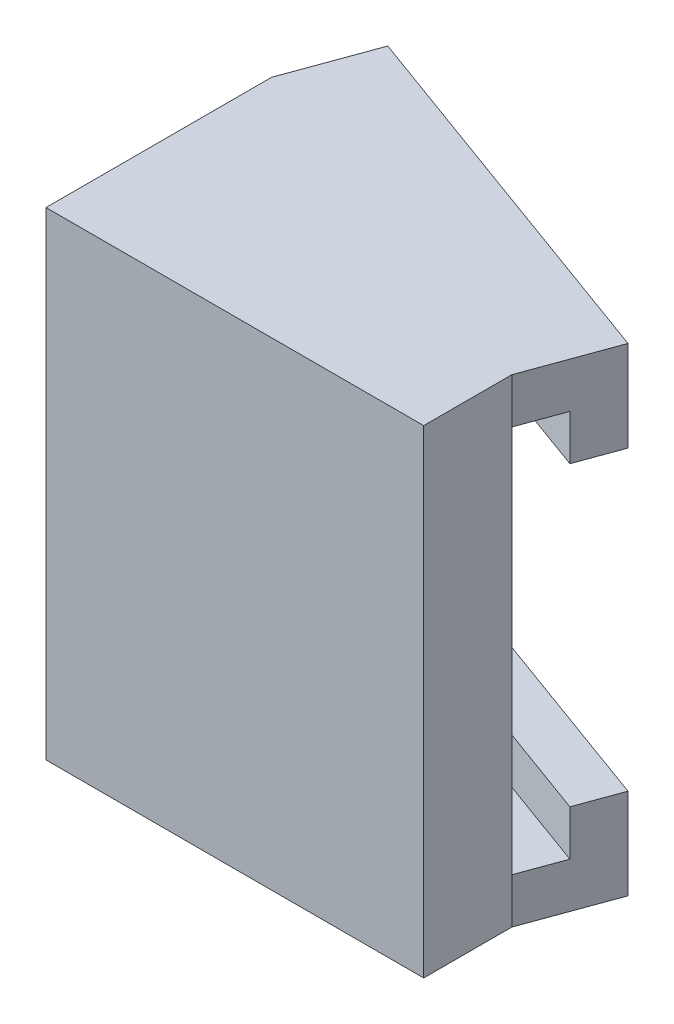
from build123d import *

# Parameters (mm, degrees)
SKIZZE1_W                       = 15
SKIZZE1_H                       = 19
AUFSATZ_LINEAR_AUSTRAGEN1_DEPTH = 3
AUFSATZ_LINEAR_AUSTRAGEN2_DEPTH = 19
SKIZZE5_R                       = 3
SCHNITT_LINEAR_AUSTRAGEN1_DEPTH = 3
SKIZZE6_W                       = 15
SKIZZE6_H                       = 19
AUFSATZ_LINEAR_AUSTRAGEN3_DEPTH = 0.5
SKIZZE7_W                       = 15.962666587
SKIZZE7_H                       = 1.8
AUFSATZ_LINEAR_AUSTRAGEN4_DEPTH = 3.6
AUFSATZ_LINEAR_AUSTRAGEN5_DEPTH = 1.8
AUFSATZ_LINEAR_AUSTRAGEN6_DEPTH = 1.8


with BuildPart() as part:
    # Skizze1 → Aufsatz-Linear austragen1 (new body)
    with BuildSketch(Plane.XY):
        Rectangle(SKIZZE1_W, SKIZZE1_H)
    extrude(amount=AUFSATZ_LINEAR_AUSTRAGEN1_DEPTH)

    # Skizze3 → Aufsatz-Linear austragen2 (add)
    with BuildSketch(Plane(origin=(0, 9.5, 0), x_dir=(1, 0, 0), z_dir=(0, 1, 0))):
        Polygon((-7.5, 0), (-7.5, 5.459553514), (7.5, 0), align=None)
    extrude(amount=-AUFSATZ_LINEAR_AUSTRAGEN2_DEPTH)

    # Skizze5 → Schnitt-Linear austragen1 (cut)
    with BuildSketch(Plane.XY.offset(3)):
        Circle(SKIZZE5_R)
    extrude(amount=-SCHNITT_LINEAR_AUSTRAGEN1_DEPTH, mode=Mode.SUBTRACT)

    # Skizze6 → Aufsatz-Linear austragen3 (add)
    with BuildSketch(Plane.XY.offset(3)):
        Rectangle(SKIZZE6_W, SKIZZE6_H)
    extrude(amount=AUFSATZ_LINEAR_AUSTRAGEN3_DEPTH)

    # Skizze7 → Aufsatz-Linear austragen4 (add)
    with BuildSketch(Plane(origin=(0.877333338, 0, -2.410453536), x_dir=(-0.939692621, 0, -0.342020143), z_dir=(0.342020143, 0, -0.939692621))):
        with Locations((0.933638638, 8.6)):
            Rectangle(SKIZZE7_W, SKIZZE7_H)
        with Locations((0.933638638, -8.6)):
            Rectangle(SKIZZE7_W, SKIZZE7_H)
    extrude(amount=AUFSATZ_LINEAR_AUSTRAGEN4_DEPTH)

    # Skizze10 → Aufsatz-Linear austragen5 (add)
    with BuildSketch(Plane.XZ.offset(-7.7)):
        Polygon((8.731272516, -3.382893435), (8.115636258, -1.691446717), (-6.884363742, -7.151000231), (-6.268727484, -8.842446949), align=None)
    extrude(amount=AUFSATZ_LINEAR_AUSTRAGEN5_DEPTH)

    # Skizze9 → Aufsatz-Linear austragen6 (add)
    with BuildSketch(Plane(origin=(0, -7.7, 0), x_dir=(1, 0, 0), z_dir=(0, 1, 0))):
        Polygon((8.115636258, 1.691446717), (-6.884363742, 7.151000231), (-6.268727484, 8.842446949), (8.731272516, 3.382893435), align=None)
    extrude(amount=AUFSATZ_LINEAR_AUSTRAGEN6_DEPTH)


solid = part.part
